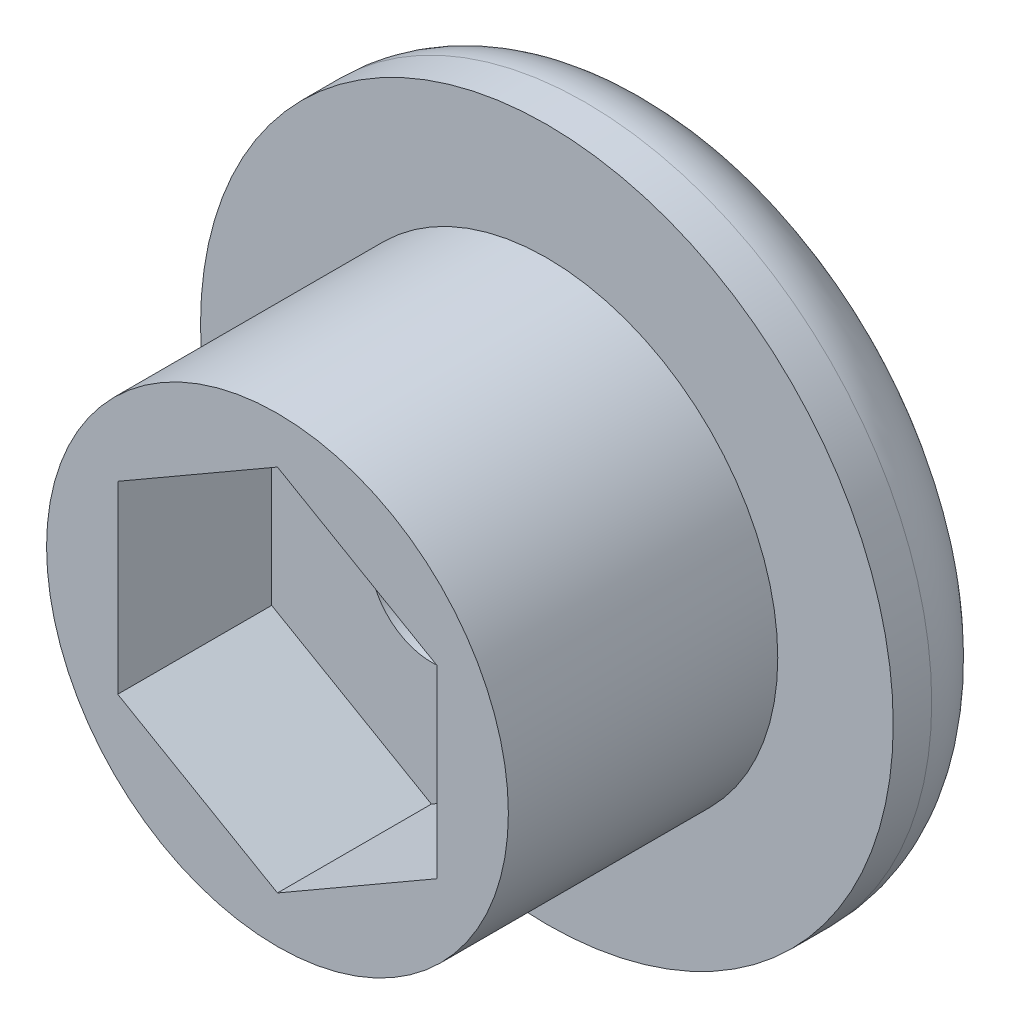
from build123d import *

# Parameters (mm, degrees)
SALIENTE_EXTRUIR1_START = -7
CROQUIS1_R              = 6
SALIENTE_EXTRUIR1_DEPTH = 4
CROQUIS2_R              = 6
SALIENTE_EXTRUIR2_DEPTH = 3
CROQUIS3_R              = 9
SALIENTE_EXTRUIR3_DEPTH = 3
CROQUIS4_R              = 1.6
CORTAR_EXTRUIR1_DEPTH   = 11.5
CROQUIS5_R              = 3
CORTAR_EXTRUIR2_DEPTH   = 3
REDONDEO1_R             = 2


with BuildPart() as part:
    # Croquis1 → Saliente-Extruir1 (new body)
    with BuildSketch(Plane(origin=(0, 0, 34.55), x_dir=(-1, 0, 0), z_dir=(0, 0, -1)).offset(SALIENTE_EXTRUIR1_START)):
        with Locations((13.509321031, -3.657231325)):
            Circle(CROQUIS1_R)
        Polygon((9.359321031, -1.261227707), (9.359321031, -6.053234942), (13.509321031, -8.449238559), (17.659321031, -6.053234942), (17.659321031, -1.261227707), (13.509321031, 1.13477591), align=None, mode=Mode.SUBTRACT)
    extrude(amount=SALIENTE_EXTRUIR1_DEPTH)

    # Croquis2 → Saliente-Extruir2 (add)
    with BuildSketch(Plane(origin=(0, 0, 37.55), x_dir=(-1, 0, 0), z_dir=(0, 0, -1))):
        with Locations((13.509321031, -3.657231325)):
            Circle(CROQUIS2_R)
    extrude(amount=SALIENTE_EXTRUIR2_DEPTH)

    # Croquis3 → Saliente-Extruir3 (add)
    with BuildSketch(Plane(origin=(0, 0, 34.55), x_dir=(-1, 0, 0), z_dir=(0, 0, -1))):
        with Locations((13.509321031, -3.657231325)):
            Circle(CROQUIS3_R)
    extrude(amount=SALIENTE_EXTRUIR3_DEPTH)

    # Croquis4 → Cortar-Extruir1 (cut)
    with BuildSketch(Plane(origin=(0, 0, 31.55), x_dir=(-1, 0, 0), z_dir=(0, 0, -1))):
        with Locations((13.509321031, -3.657231325)):
            Circle(CROQUIS4_R)
    extrude(amount=-CORTAR_EXTRUIR1_DEPTH, mode=Mode.SUBTRACT)

    # Croquis5 → Cortar-Extruir2 (cut)
    with BuildSketch(Plane(origin=(0, 0, 31.55), x_dir=(-1, 0, 0), z_dir=(0, 0, -1))):
        with Locations((13.509321031, -3.657231325)):
            Circle(CROQUIS5_R)
    extrude(amount=-CORTAR_EXTRUIR2_DEPTH, mode=Mode.SUBTRACT)

    # Redondeo1
    redondeo1_edges = [part.edges().sort_by_distance(p)[0] for p in [
        (-4.509321031, -3.657231325, 31.55),
    ]]
    fillet(redondeo1_edges, radius=REDONDEO1_R)


solid = part.part
